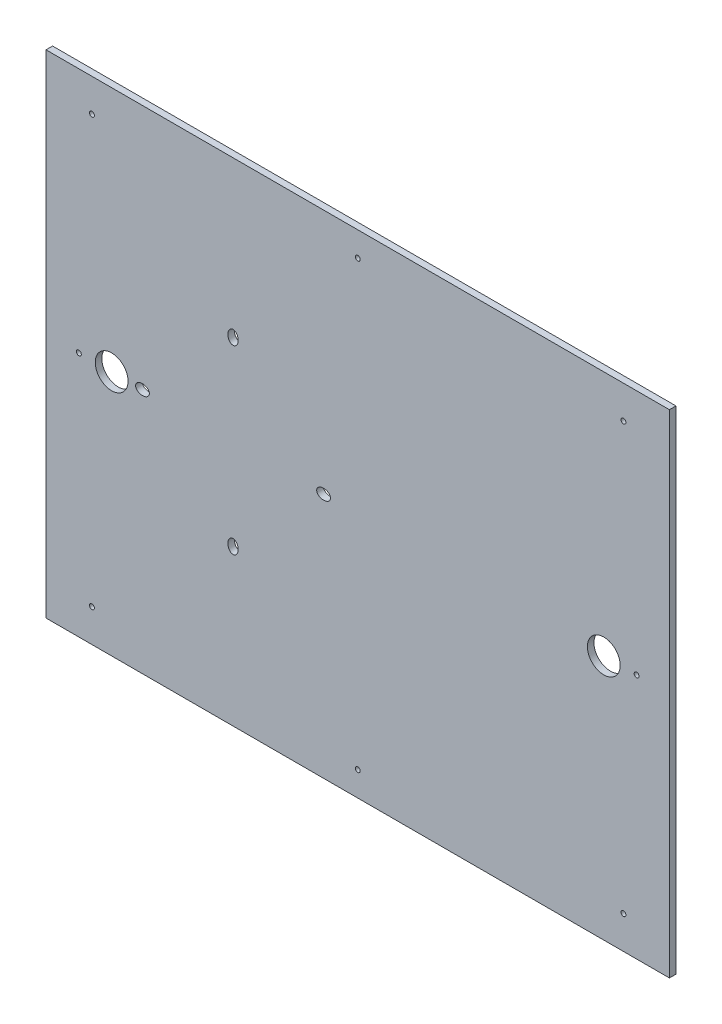
from build123d import *

# Parameters (mm, degrees)
SKETCH3_W           = 380
SKETCH3_H           = 300
BOSS_EXTRUDE1_DEPTH = 4
HOLE2_D             = 20
HOLE2_DEPTH         = 100
SKETCH10_R          = 1.5
CUT_EXTRUDE1_DEPTH  = 4
SKETCH11_R          = 1.5
CUT_EXTRUDE2_DEPTH  = 4
SKETCH12_RX         = 4.2
SKETCH12_RY         = 3.15
CUT_EXTRUDE9_DEPTH  = 4


with BuildPart() as part:
    # Sketch3 → Boss-Extrude1 (new body)
    with BuildSketch(Plane.XY):
        with Locations((-123.149881766, 47.763665148)):
            Rectangle(SKETCH3_W, SKETCH3_H)
    extrude(amount=BOSS_EXTRUDE1_DEPTH)

    # Hole2
    with Locations(Plane(origin=(-273.149881766, 47.763665148, 4), x_dir=(1, 0, 0), z_dir=(0, 0, 1))):
        with Locations((0, 0), (300, 0)):
            Hole(HOLE2_D / 2, depth=HOLE2_DEPTH)

    # Sketch10 → Cut-Extrude1 (cut)
    with BuildSketch(Plane(origin=(0, 0, 0), x_dir=(-1, 0, 0), z_dir=(0, 0, -1))):
        with Locations((285.149881766, 177.763665148)):
            Circle(SKETCH10_R)
        with Locations((-38.850118234, 177.763665148)):
            Circle(SKETCH10_R)
        with Locations((-38.850118234, -82.236334852)):
            Circle(SKETCH10_R)
        with Locations((285.149881766, -82.236334852)):
            Circle(SKETCH10_R)
    extrude(amount=-CUT_EXTRUDE1_DEPTH, mode=Mode.SUBTRACT)

    # Sketch11 → Cut-Extrude2 (cut)
    with BuildSketch(Plane(origin=(0, 0, 0), x_dir=(-1, 0, 0), z_dir=(0, 0, -1))):
        with Locations((293.149881766, 47.763665148)):
            Circle(SKETCH11_R)
        with Locations((123.149881766, 182.763665148)):
            Circle(SKETCH11_R)
        with Locations((-46.850118234, 47.763665148)):
            Circle(SKETCH11_R)
        with Locations((123.149881766, -87.236334852)):
            Circle(SKETCH11_R)
    extrude(amount=-CUT_EXTRUDE2_DEPTH, mode=Mode.SUBTRACT)

    # Sketch12 → Cut-Extrude9 (cut)
    with BuildSketch(Plane(origin=(0, 0, 0), x_dir=(-1, 0, 0), z_dir=(0, 0, -1))):
        with Locations(Location((199.149881766, -7.436334852), (0, 0, 90))):
            Ellipse(SKETCH12_RX, SKETCH12_RY)
        with Locations(Location((143.949881766, 47.763665148), (0, 0, 0))):
            Ellipse(SKETCH12_RX, SKETCH12_RY)
        with Locations(Location((199.149881766, 102.963665148), (0, 0, -90))):
            Ellipse(SKETCH12_RX, SKETCH12_RY)
        with Locations(Location((254.349881766, 47.763665148), (0, 0, 180))):
            Ellipse(SKETCH12_RX, SKETCH12_RY)
    extrude(amount=-CUT_EXTRUDE9_DEPTH, mode=Mode.SUBTRACT)


solid = part.part
